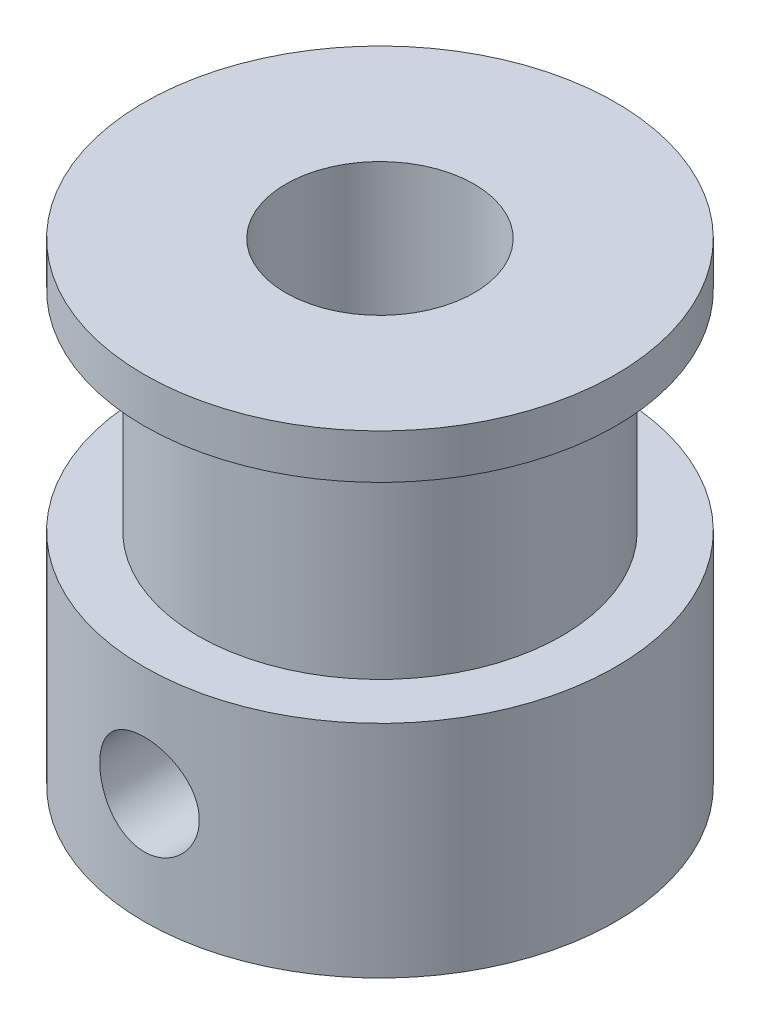
from build123d import *

# Parameters (mm, degrees)
SKETCH1_R           = 7.93
SKETCH1_R_2         = 3.17
BOSS_EXTRUDE1_DEPTH = 7.42
SKETCH2_R           = 6.12
SKETCH2_R_2         = 3.17
BOSS_EXTRUDE2_DEPTH = 7.02
SKETCH3_R           = 7.93
SKETCH3_R_2         = 3.17
BOSS_EXTRUDE3_DEPTH = 1.5
SKETCH4_R           = 1.675
CUT_EXTRUDE1_DEPTH  = 8.93
CIRPATTERN1_COUNT   = 2
CIRPATTERN1_ANGLE   = 90


with BuildPart() as part:
    # Sketch1 → Boss-Extrude1 (new body)
    with BuildSketch(Plane(origin=(0, 0, 0), x_dir=(1, 0, 0), z_dir=(0, 1, 0))):
        Circle(SKETCH1_R)
        Circle(SKETCH1_R_2, mode=Mode.SUBTRACT)
    extrude(amount=BOSS_EXTRUDE1_DEPTH)

    # Sketch2 → Boss-Extrude2 (add)
    with BuildSketch(Plane(origin=(0, 7.42, 0), x_dir=(1, 0, 0), z_dir=(0, 1, 0))):
        Circle(SKETCH2_R)
        Circle(SKETCH2_R_2, mode=Mode.SUBTRACT)
    extrude(amount=BOSS_EXTRUDE2_DEPTH)

    # Sketch3 → Boss-Extrude3 (add)
    with BuildSketch(Plane(origin=(0, 14.44, 0), x_dir=(1, 0, 0), z_dir=(0, 1, 0))):
        Circle(SKETCH3_R)
        Circle(SKETCH3_R_2, mode=Mode.SUBTRACT)
    extrude(amount=BOSS_EXTRUDE3_DEPTH)

    # Sketch4 → Cut-Extrude1 (cut, through all)
    with BuildSketch(Plane(origin=(0, 0, 0), x_dir=(0, 0, -1), z_dir=(1, 0, 0))):
        with Locations((0, 3.71)):
            Circle(SKETCH4_R)
    cut_extrude1 = extrude(amount=-CUT_EXTRUDE1_DEPTH, mode=Mode.SUBTRACT)

    # CirPattern1: Cut-Extrude1 ×2 about axis
    cirpattern1_axis = Axis((0, 7.42, 0), (0, 1, 0))
    for i in range(1, CIRPATTERN1_COUNT):
        add(cut_extrude1.rotate(cirpattern1_axis, i * CIRPATTERN1_ANGLE / (CIRPATTERN1_COUNT - 1)), mode=Mode.SUBTRACT)


solid = part.part
